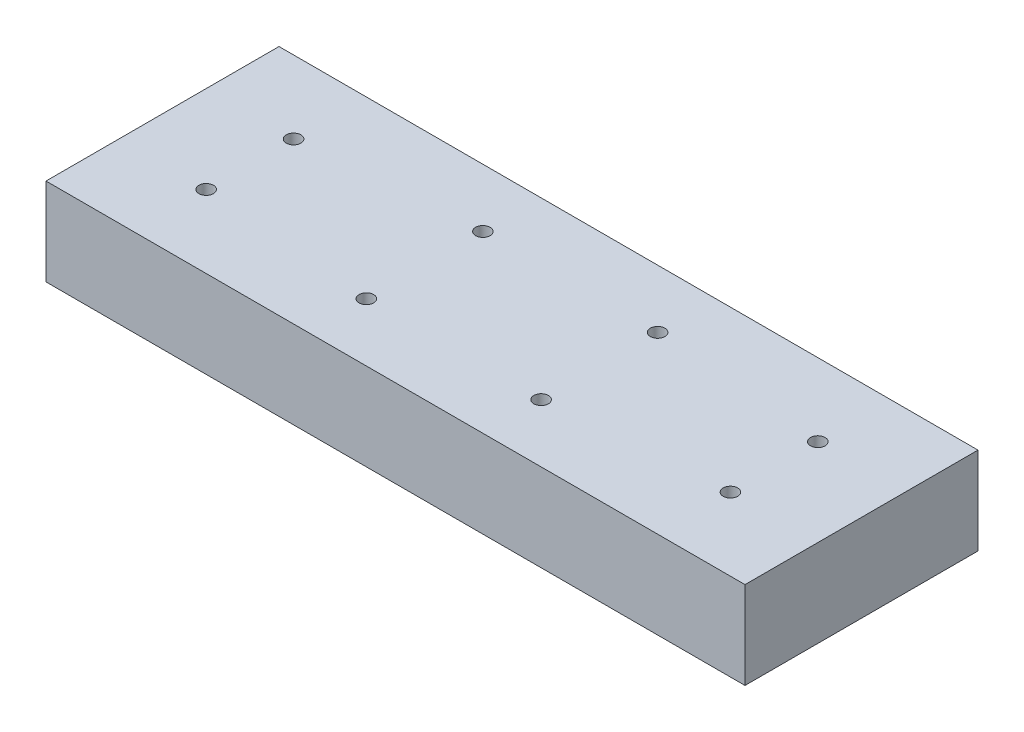
from build123d import *

# Parameters (mm, degrees)
SKETCH1_W           = 152.4
SKETCH1_H           = 50.8
SKETCH1_R           = 1.5875
BOSS_EXTRUDE1_DEPTH = 19.05
SKETCH2_R           = 5.55625
CUT_EXTRUDE1_DEPTH  = 6.35


with BuildPart() as part:
    # Sketch1 → Boss-Extrude1 (new body)
    with BuildSketch(Plane(origin=(0, 0, 0), x_dir=(1, 0, 0), z_dir=(0, 1, 0))):
        with Locations((76.2, -25.4)):
            Rectangle(SKETCH1_W, SKETCH1_H)
        with Locations(Location((57.15, -12.7, 0), (0, 0, 270))):  # turned: the seam where the file's is
            Circle(SKETCH1_R, mode=Mode.SUBTRACT)
        with Locations(Location((57.15, -38.1, 0), (0, 0, 270))):  # turned: the seam where the file's is
            Circle(SKETCH1_R, mode=Mode.SUBTRACT)
        with Locations(Location((95.25, -12.7, 0), (0, 0, 270))):  # turned: the seam where the file's is
            Circle(SKETCH1_R, mode=Mode.SUBTRACT)
        with Locations(Location((95.25, -38.1, 0), (0, 0, 270))):  # turned: the seam where the file's is
            Circle(SKETCH1_R, mode=Mode.SUBTRACT)
        with Locations(Location((19.05, -15.875, 0), (0, 0, 270))):  # turned: the seam where the file's is
            Circle(SKETCH1_R, mode=Mode.SUBTRACT)
        with Locations(Location((19.05, -34.925, 0), (0, 0, 270))):  # turned: the seam where the file's is
            Circle(SKETCH1_R, mode=Mode.SUBTRACT)
        with Locations(Location((133.35, -15.875, 0), (0, 0, 270))):  # turned: the seam where the file's is
            Circle(SKETCH1_R, mode=Mode.SUBTRACT)
        with Locations(Location((133.35, -34.925, 0), (0, 0, 270))):  # turned: the seam where the file's is
            Circle(SKETCH1_R, mode=Mode.SUBTRACT)
    extrude(amount=BOSS_EXTRUDE1_DEPTH)

    # Sketch2 → Cut-Extrude1 (cut)
    with BuildSketch(Plane(origin=(0, 0, 0), x_dir=(-1, 0, 0), z_dir=(0, -1, 0))):
        with Locations(Location((-19.05, -34.925, 0), (0, 0, 90))):  # turned: the seam where the file's is
            Circle(SKETCH2_R)
        with Locations(Location((-19.05, -15.875, 0), (0, 0, 90))):  # turned: the seam where the file's is
            Circle(SKETCH2_R)
        with Locations(Location((-57.15, -38.1, 0), (0, 0, 90))):  # turned: the seam where the file's is
            Circle(SKETCH2_R)
        with Locations(Location((-57.15, -12.7, 0), (0, 0, 90))):  # turned: the seam where the file's is
            Circle(SKETCH2_R)
        with Locations(Location((-95.25, -38.1, 0), (0, 0, 90))):  # turned: the seam where the file's is
            Circle(SKETCH2_R)
        with Locations(Location((-95.25, -12.7, 0), (0, 0, 90))):  # turned: the seam where the file's is
            Circle(SKETCH2_R)
        with Locations(Location((-133.35, -15.875, 0), (0, 0, 90))):  # turned: the seam where the file's is
            Circle(SKETCH2_R)
        with Locations(Location((-133.35, -34.925, 0), (0, 0, 90))):  # turned: the seam where the file's is
            Circle(SKETCH2_R)
    extrude(amount=-CUT_EXTRUDE1_DEPTH, mode=Mode.SUBTRACT)


solid = part.part
